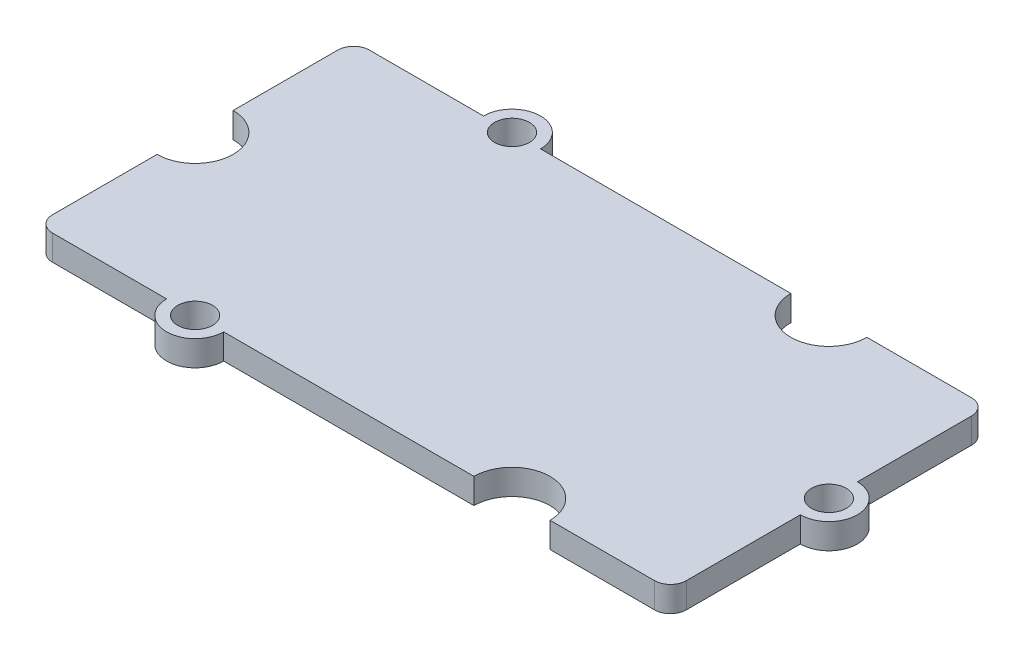
from build123d import *

# Parameters (mm, degrees)
ESQUISSE1_R        = 1.1
BOSS_EXTRU_1_DEPTH = 1.6


with BuildPart() as part:
    # Esquisse1 → Boss.-Extru.1 (new body)
    with BuildSketch(Plane(origin=(0, 0, 0), x_dir=(1, 0, 0), z_dir=(0, 1, 0))):
        with BuildLine():
            ThreePointArc((-11.8, -10), (-10, -11.8), (-8.2, -10))
            Line((-8.2, -10), (7.6, -10))
            ThreePointArc((7.6, -10), (10, -7.6), (12.4, -10))
            Line((12.4, -10), (19, -10))
            ThreePointArc((19, -10), (19.707106781, -9.707106781), (20, -9))
            Line((20, -9), (20, -1.8))
            ThreePointArc((20, -1.8), (21.8, 0), (20, 1.8))
            Line((20, 1.8), (20, 9))
            ThreePointArc((20, 9), (19.707106781, 9.707106781), (19, 10))
            Line((19, 10), (12.4, 10))
            ThreePointArc((12.4, 10), (10, 7.6), (7.6, 10))
            Line((7.6, 10), (-8.2, 10))
            ThreePointArc((-8.2, 10), (-10, 11.8), (-11.8, 10))
            Line((-11.8, 10), (-19, 10))
            ThreePointArc((-19, 10), (-19.707106781, 9.707106781), (-20, 9))
            Line((-20, 9), (-20, 2.4))
            ThreePointArc((-20, 2.4), (-17.6, 0), (-20, -2.4))
            Line((-20, -2.4), (-20, -9))
            ThreePointArc((-20, -9), (-19.707106781, -9.707106781), (-19, -10))
            Line((-19, -10), (-11.8, -10))
        make_face()
        with Locations(Location((-10, -10, 0), (0, 0, 270))):  # turned: the seam where the file's is
            Circle(ESQUISSE1_R, mode=Mode.SUBTRACT)
        with Locations(Location((20, 0, 0), (0, 0, 270))):  # turned: the seam where the file's is
            Circle(ESQUISSE1_R, mode=Mode.SUBTRACT)
        with Locations(Location((-10, 10, 0), (0, 0, 270))):  # turned: the seam where the file's is
            Circle(ESQUISSE1_R, mode=Mode.SUBTRACT)
    extrude(amount=BOSS_EXTRU_1_DEPTH)


solid = part.part
